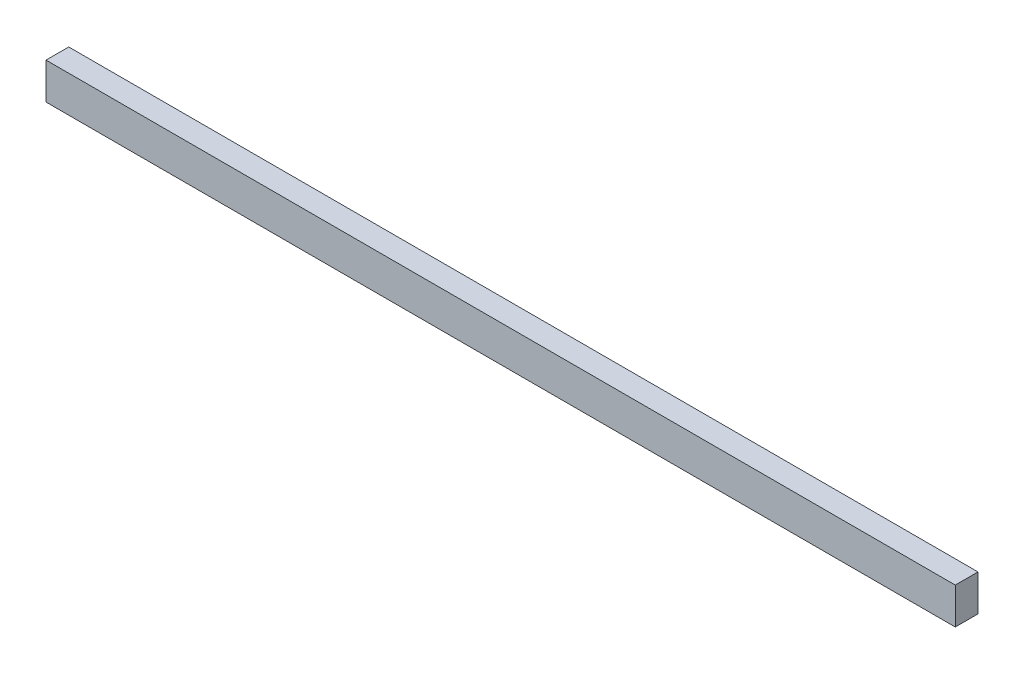
from build123d import *

# Parameters (mm, degrees)
SKETCH1_W           = 254
SKETCH1_H           = 10.16
BOSS_EXTRUDE1_DEPTH = 6.35


with BuildPart() as part:
    # Sketch1 → Boss-Extrude1 (new body)
    with BuildSketch(Plane.XY):
        with Locations((127, 5.08)):
            Rectangle(SKETCH1_W, SKETCH1_H)
    extrude(amount=BOSS_EXTRUDE1_DEPTH)


solid = part.part
